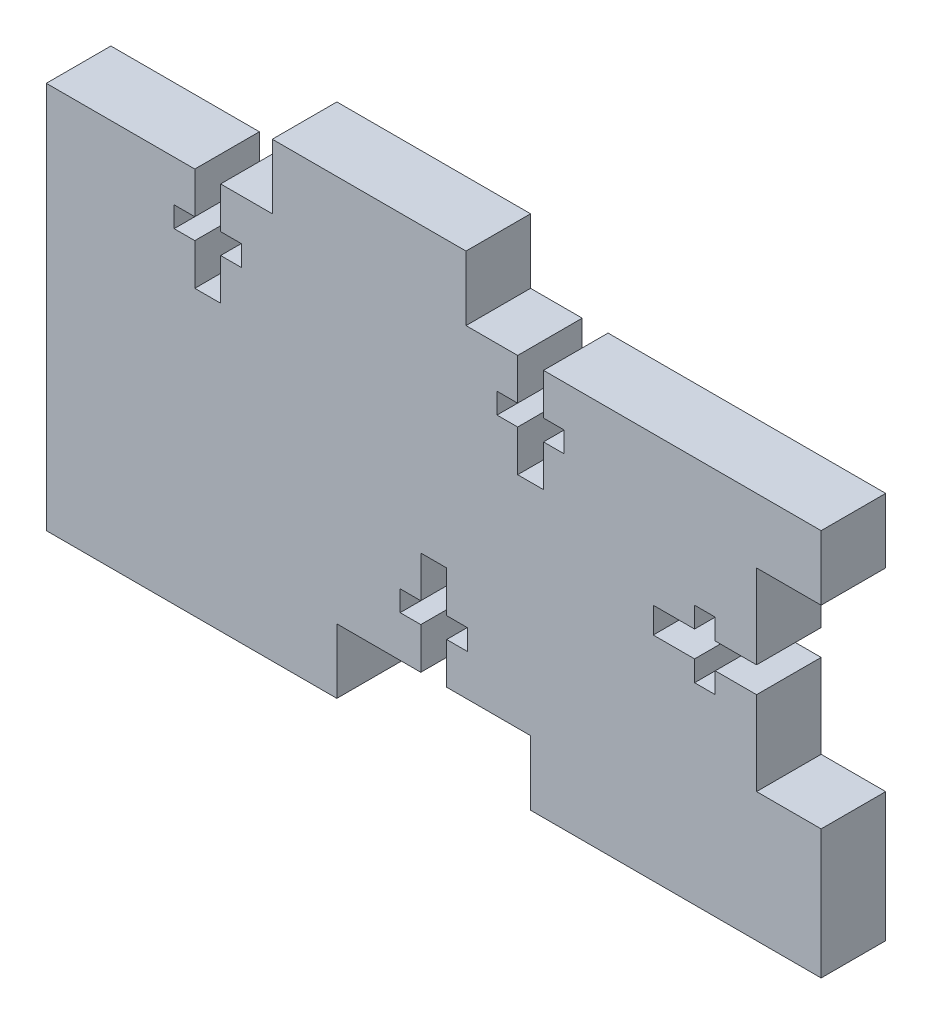
from build123d import *

# Parameters (mm, degrees)
SKETCH1_W           = 76.2
SKETCH1_H           = 31.75
BOSS_EXTRUDE1_DEPTH = 6.35
SKETCH2_W           = 19.05
SKETCH2_H           = 6.35
BOSS_EXTRUDE2_DEPTH = 6.35
CUT_EXTRUDE1_DEPTH  = 6.35
CUT_EXTRUDE4_DEPTH  = 6.35
SKETCH5_W           = 76.2
SKETCH5_H           = 6.35
BOSS_EXTRUDE3_DEPTH = 6.35
CUT_EXTRUDE5_DEPTH  = 6.35


with BuildPart() as part:
    # Sketch1 → Boss-Extrude1 (new body)
    with BuildSketch(Plane.XY):
        Rectangle(SKETCH1_W, SKETCH1_H)
    extrude(amount=BOSS_EXTRUDE1_DEPTH)

    # Sketch2 → Boss-Extrude2 (add)
    with BuildSketch(Plane.XY.offset(6.35)):
        with Locations((-6.35, 19.05)):
            Rectangle(SKETCH2_W, SKETCH2_H)
    extrude(amount=-BOSS_EXTRUDE2_DEPTH)

    # Sketch3 → Cut-Extrude1 (cut)
    with BuildSketch(Plane.XY.offset(6.35)):
        Polygon((-20.955, 11.811), (-18.923, 11.811), (-18.923, 9.779), (-20.955, 9.779), (-20.955, 5.715), (-23.495, 5.715), (-23.495, 9.779), (-25.527, 9.779), (-25.527, 11.811), (-23.495, 11.811), (-23.495, 15.875), (-20.955, 15.875), align=None)
        Polygon((8.255, 9.779), (8.255, 5.715), (10.795, 5.715), (10.795, 9.779), (12.827, 9.779), (12.827, 11.811), (10.795, 11.811), (10.795, 15.875), (8.255, 15.875), (8.255, 11.811), (6.223, 11.811), (6.223, 9.779), align=None)
    extrude(amount=-CUT_EXTRUDE1_DEPTH, mode=Mode.SUBTRACT)

    # Sketch4 → Cut-Extrude4 (cut)
    with BuildSketch(Plane.XY.offset(6.35)):
        Polygon((31.75, -9.525), (38.1, -9.525), (38.1, 9.525), (31.75, 9.525), (31.75, 1.27), (27.686, 1.27), (27.686, 3.302), (25.654, 3.302), (25.654, 1.27), (21.59, 1.27), (21.59, -1.27), (25.654, -1.27), (25.654, -3.302), (27.686, -3.302), (27.686, -1.27), (31.75, -1.27), align=None)
    extrude(amount=-CUT_EXTRUDE4_DEPTH, mode=Mode.SUBTRACT)

    # Sketch5 → Boss-Extrude3 (add)
    with BuildSketch(Plane.XY.offset(6.35)):
        with Locations((0, -19.05)):
            Rectangle(SKETCH5_W, SKETCH5_H)
    extrude(amount=-BOSS_EXTRUDE3_DEPTH)

    # Sketch6 → Cut-Extrude5 (cut)
    with BuildSketch(Plane.XY.offset(6.35)):
        Polygon((-9.525, -22.225), (9.525, -22.225), (9.525, -15.875), (1.27, -15.875), (1.27, -11.811), (3.302, -11.811), (3.302, -9.779), (1.27, -9.779), (1.27, -5.715), (-1.27, -5.715), (-1.27, -9.779), (-3.302, -9.779), (-3.302, -11.811), (-1.27, -11.811), (-1.27, -15.875), (-9.525, -15.875), align=None)
    extrude(amount=-CUT_EXTRUDE5_DEPTH, mode=Mode.SUBTRACT)


solid = part.part
